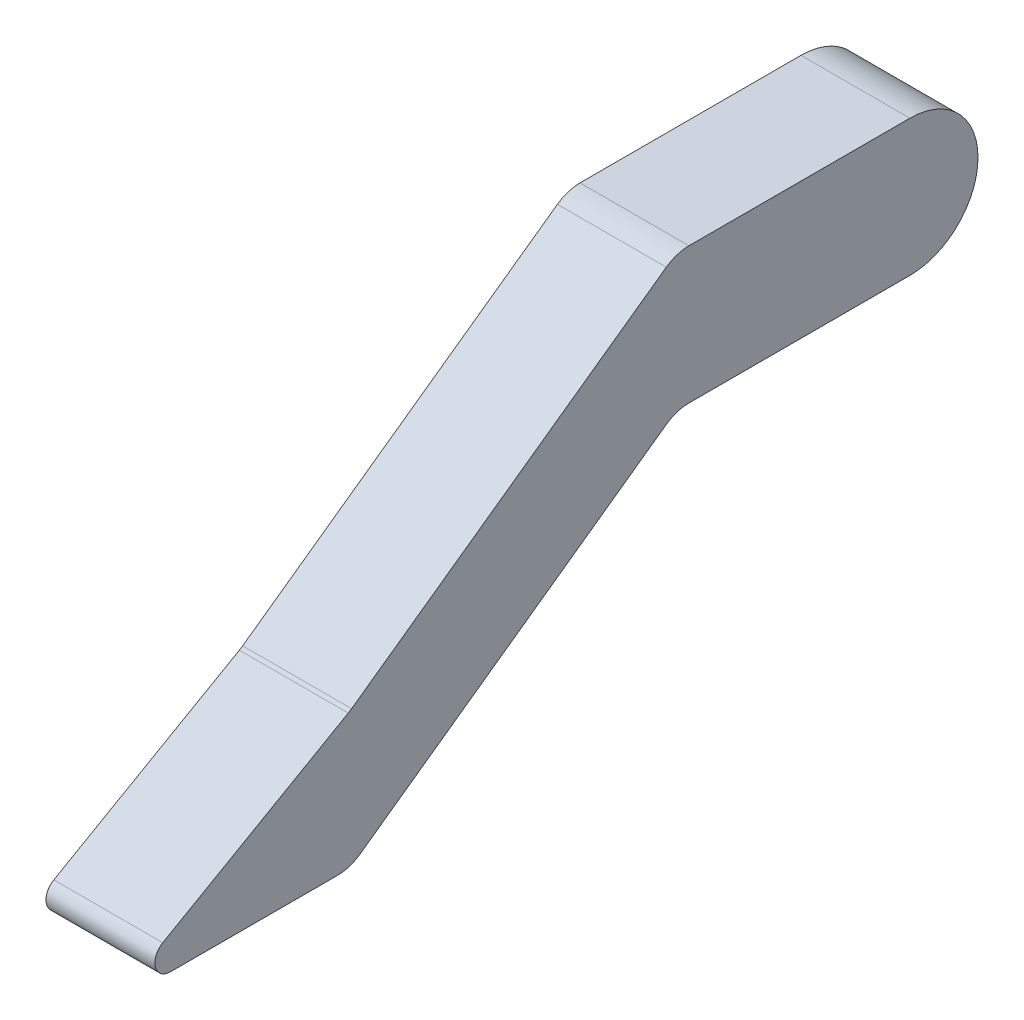
from build123d import *

# Parameters (mm, degrees)
BOSS_EXTRUDE1_DEPTH = 17.78


with BuildPart() as part:
    # Sketch1 → Boss-Extrude1 (new body, symmetric)
    with BuildSketch(Plane(origin=(0, 0, 0), x_dir=(0, 0, -1), z_dir=(1, 0, 0))):
        with BuildLine():
            Line((-34.027638145, 22.225), (38.1, 22.225))
            ThreePointArc((38.1, 22.225), (60.325, 0), (38.1, -22.225))
            Line((38.1, -22.225), (-34.027638145, -22.225))
            ThreePointArc((-34.027638145, -22.225), (-37.905512075, -22.831526811), (-41.41298687, -24.593174207))
            Line((-41.41298687, -24.593174207), (-141.36658517, -96.041550766))
            ThreePointArc((-141.36658517, -96.041550766), (-144.874059965, -97.803198163), (-148.751933895, -98.409724974))
            Line((-148.751933895, -98.409724974), (-203.2806723, -98.409724974))
            ThreePointArc((-203.2806723, -98.409724974), (-208.190227055, -94.634589756), (-205.802839661, -88.920068321))
            Line((-205.802839661, -88.920068321), (-145.237041742, -54.278577891))
            ThreePointArc((-145.237041742, -54.278577891), (-144.688329899, -53.946063756), (-144.157111422, -53.586262051))
            Line((-144.157111422, -53.586262051), (-41.41298687, 19.856825793))
            ThreePointArc((-41.41298687, 19.856825793), (-37.905512075, 21.618473189), (-34.027638145, 22.225))
        make_face()
    extrude(amount=BOSS_EXTRUDE1_DEPTH, both=True)


solid = part.part
